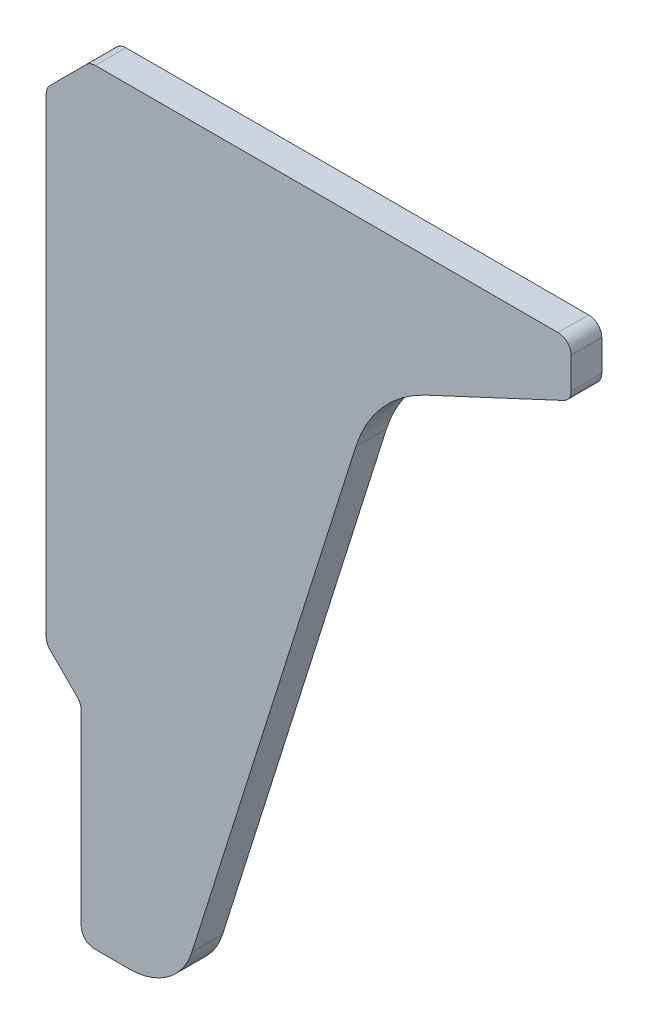
from build123d import *

# Parameters (mm, degrees)
EXTRUDE1_DEPTH = 7


with BuildPart() as part:
    # Sketch1 → Extrude1 (new body)
    with BuildSketch(Plane.XY):
        with BuildLine():
            Line((-8, 56.242640687), (-8, 163.757359313))
            ThreePointArc((-8, 163.757359313), (-7.771638598, 164.90540961), (-7.121320344, 165.878679656))
            Line((-7.121320344, 165.878679656), (1.121320344, 174.121320344))
            ThreePointArc((1.121320344, 174.121320344), (2.09459039, 174.771638598), (3.242640687, 175))
            Line((3.242640687, 175), (109, 175))
            ThreePointArc((109, 175), (111.121320344, 174.121320344), (112, 172))
            Line((112, 172), (112, 164.911210782))
            ThreePointArc((112, 164.911210782), (111.530174337, 163.299311957), (110.267854785, 162.192287421))
            Line((110.267854785, 162.192287421), (78.702722562, 147.473224535))
            ThreePointArc((78.702722562, 147.473224535), (68.82607619, 140.064365377), (62.769761892, 129.305164909))
            Line((62.769761892, 129.305164909), (25.307299217, 10.489413007))
            ThreePointArc((25.307299217, 10.489413007), (19.871189682, 2.903330936), (11.001544956, 0))
            Line((11.001544956, 0), (3, 0))
            ThreePointArc((3, 0), (0.878679656, 0.878679656), (0, 3))
            Line((0, 3), (0, 45.757359313))
            ThreePointArc((0, 45.757359313), (-0.228361402, 46.90540961), (-0.878679656, 47.878679656))
            Line((-0.878679656, 47.878679656), (-7.121320344, 54.121320344))
            ThreePointArc((-7.121320344, 54.121320344), (-7.771638598, 55.09459039), (-8, 56.242640687))
        make_face()
    extrude(amount=EXTRUDE1_DEPTH)


solid = part.part
